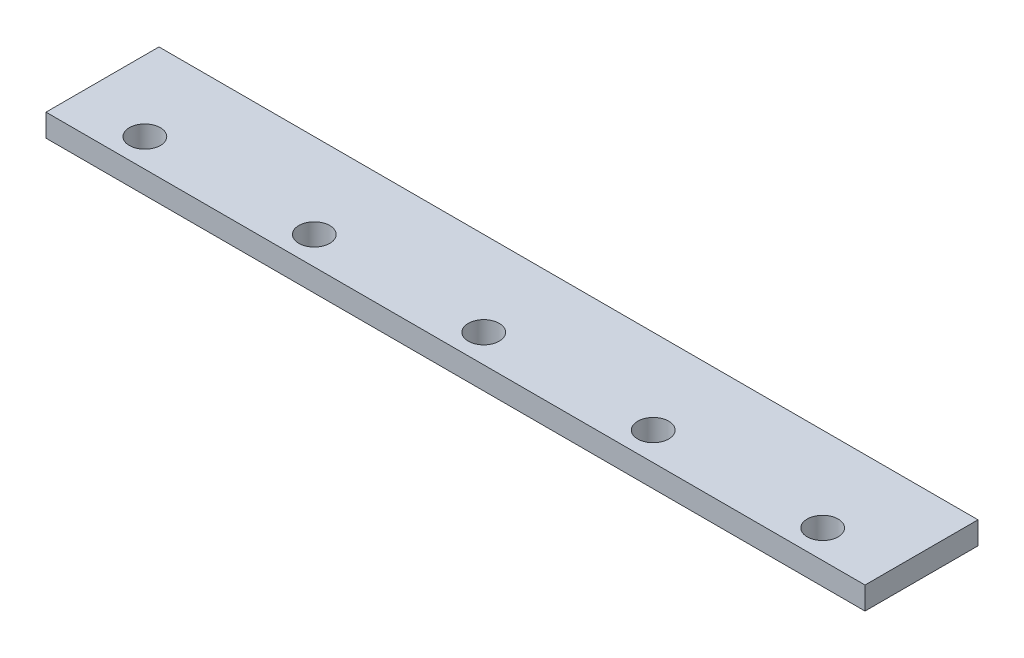
from build123d import *

# Parameters (mm, degrees)
SKETCH1_W           = 5800
SKETCH1_H           = 800
BOSS_EXTRUDE1_DEPTH = 160
SKETCH2_R           = 109.705286938
CUT_EXTRUDE1_DEPTH  = 160
LPATTERN1_COUNT     = 5
LPATTERN1_PITCH     = 1200


with BuildPart() as part:
    # Sketch1 → Boss-Extrude1 (new body)
    with BuildSketch(Plane(origin=(0, 0, 0), x_dir=(1, 0, 0), z_dir=(0, 1, 0))):
        with Locations((2920.315236427, -1088.091068301)):
            Rectangle(SKETCH1_W, SKETCH1_H)
    extrude(amount=BOSS_EXTRUDE1_DEPTH)

    # Sketch2 → Cut-Extrude1 (cut)
    with BuildSketch(Plane(origin=(0, 160, 0), x_dir=(1, 0, 0), z_dir=(0, 1, 0))):
        with Locations(Location((520.315236427, -1288.091068301, 0), (0, 0, 270))):  # turned: the seam where the file's is
            Circle(SKETCH2_R)
    cut_extrude1 = extrude(amount=-CUT_EXTRUDE1_DEPTH, mode=Mode.SUBTRACT)

    # LPattern1: Cut-Extrude1 ×5
    with Locations(*[(i * LPATTERN1_PITCH, 0, 0) for i in range(1, LPATTERN1_COUNT)]):
        add(cut_extrude1, mode=Mode.SUBTRACT)


solid = part.part
